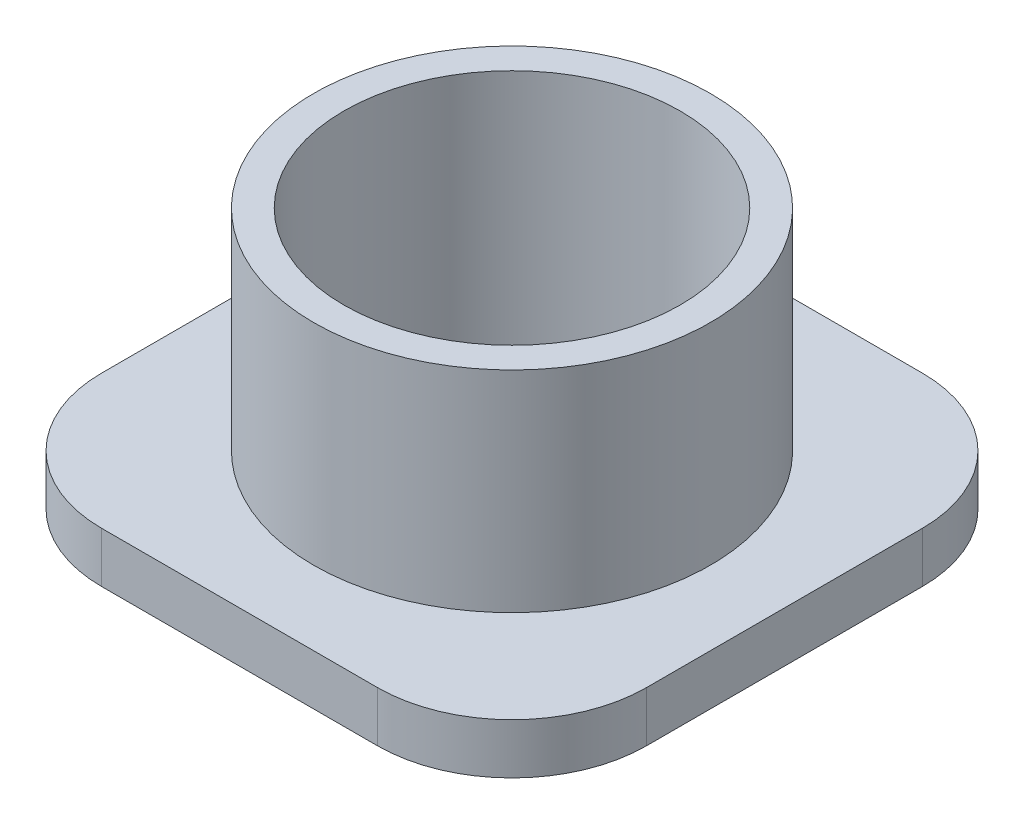
from build123d import *

# Parameters (mm, degrees)
BASE_EXTRUDE_DEPTH  = 3.81
SKETCH2_R           = 14.986
BOSS_EXTRUDE1_DEPTH = 15.875
SKETCH3_R           = 12.7
CUT_EXTRUDE1_DEPTH  = 20.685


with BuildPart() as part:
    # Sketch1 → Base-Extrude (new body)
    with BuildSketch(Plane(origin=(0, 0, 0), x_dir=(1, 0, 0), z_dir=(0, 1, 0))):
        with BuildLine():
            Line((-10.414, 20.574), (10.414, 20.574))
            ThreePointArc((10.414, 20.574), (17.598204897, 17.598204897), (20.574, 10.414))
            Line((20.574, 10.414), (20.574, -10.414))
            ThreePointArc((20.574, -10.414), (17.598204897, -17.598204897), (10.414, -20.574))
            Line((10.414, -20.574), (-10.414, -20.574))
            ThreePointArc((-10.414, -20.574), (-17.598204897, -17.598204897), (-20.574, -10.414))
            Line((-20.574, -10.414), (-20.574, 10.414))
            ThreePointArc((-20.574, 10.414), (-17.598204897, 17.598204897), (-10.414, 20.574))
        make_face()
    extrude(amount=BASE_EXTRUDE_DEPTH)

    # Sketch2 → Boss-Extrude1 (add)
    with BuildSketch(Plane(origin=(0, 3.81, 0), x_dir=(-1, 0, 0), z_dir=(0, 1, 0))):
        Circle(SKETCH2_R)
    extrude(amount=BOSS_EXTRUDE1_DEPTH)

    # Sketch3 → Cut-Extrude1 (cut, through all)
    with BuildSketch(Plane(origin=(0, 19.685, 0), x_dir=(-1, 0, 0), z_dir=(0, 1, 0))):
        Circle(SKETCH3_R)
    extrude(amount=-CUT_EXTRUDE1_DEPTH, mode=Mode.SUBTRACT)


solid = part.part
